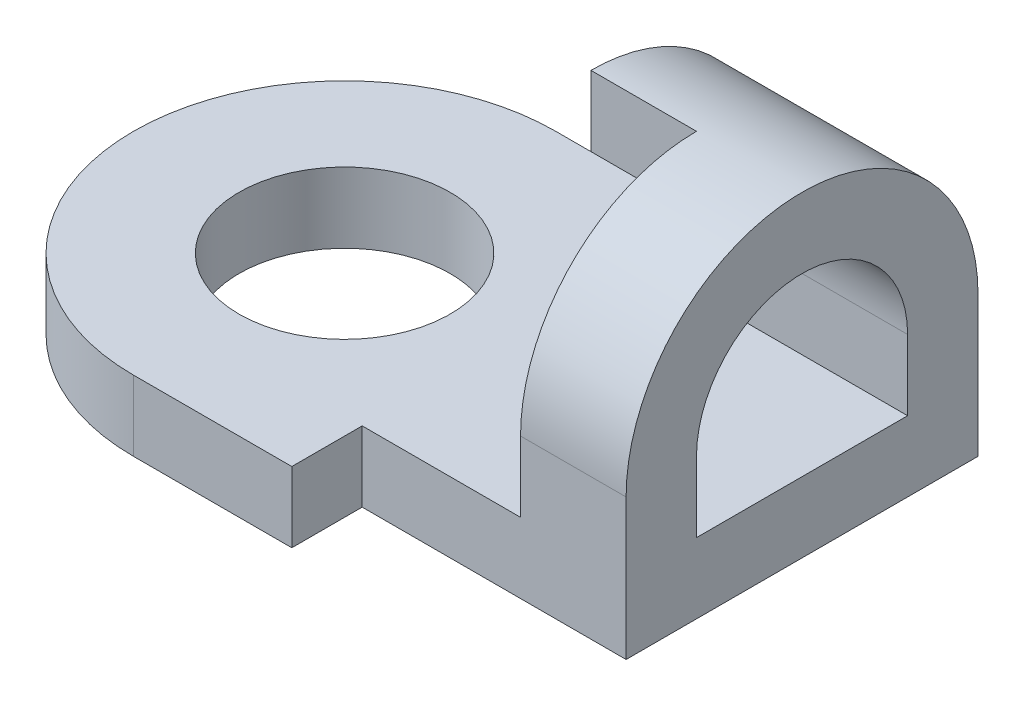
from build123d import *

# Parameters (mm, degrees)
SKETCH1_R           = 3
BOSS_EXTRUDE1_DEPTH = 2
BOSS_EXTRUDE2_DEPTH = 6
SKETCH3_W           = 5
SKETCH3_H           = 7
CUT_EXTRUDE1_DEPTH  = 3


with BuildPart() as part:
    # Sketch1 → Boss-Extrude1 (new body)
    with BuildSketch(Plane(origin=(0, 0, 0), x_dir=(1, 0, 0), z_dir=(0, 1, 0))):
        with BuildLine():
            Line((6, 6), (-6, 6))
            ThreePointArc((-6, 6), (-12, 0), (-6, -6))
            Line((-6, -6), (-1.5, -6))
            Line((-1.5, -6), (-1.5, -4))
            Line((-1.5, -4), (6, -4))
            Line((6, -4), (6, 6))
        make_face()
        with Locations((-6, 0)):
            Circle(SKETCH1_R, mode=Mode.SUBTRACT)
    extrude(amount=BOSS_EXTRUDE1_DEPTH)

    # Sketch2 → Boss-Extrude2 (add)
    with BuildSketch(Plane(origin=(6, 0, 0), x_dir=(0, 0, -1), z_dir=(1, 0, 0))):
        with BuildLine():
            Line((4, 2), (4, 4))
            ThreePointArc((4, 4), (1, 7), (-2, 4))
            Line((-2, 4), (-2, 2))
            Line((-2, 2), (-4, 2))
            Line((-4, 2), (-4, 4))
            ThreePointArc((-4, 4), (1, 9), (6, 4))
            Line((6, 4), (6, 2))
            Line((6, 2), (4, 2))
        make_face()
    extrude(amount=-BOSS_EXTRUDE2_DEPTH)

    # Sketch3 → Cut-Extrude1 (cut)
    with BuildSketch(Plane.ZY):
        with Locations((1.5, 5.5)):
            Rectangle(SKETCH3_W, SKETCH3_H)
    extrude(amount=-CUT_EXTRUDE1_DEPTH, mode=Mode.SUBTRACT)


solid = part.part
